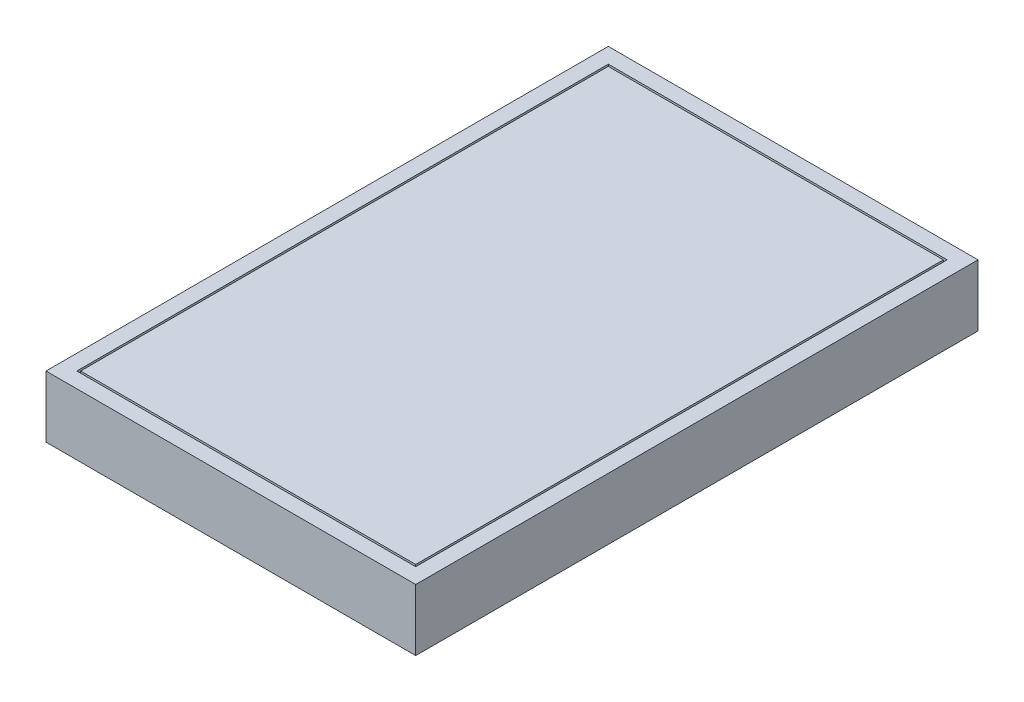
from build123d import *

# Parameters (mm, degrees)
SKETCH1_W           = 480
SKETCH1_H           = 730
BOSS_EXTRUDE1_DEPTH = 80
SKETCH2_W           = 440
SKETCH2_H           = 690
CUT_EXTRUDE1_DEPTH  = 11
SKETCH3_W           = 435
SKETCH3_H           = 685
BOSS_EXTRUDE2_DEPTH = 11


with BuildPart() as part:
    # Sketch1 → Boss-Extrude1 (new body)
    with BuildSketch(Plane.XZ.offset(60)):
        with Locations((0, 365)):
            Rectangle(SKETCH1_W, SKETCH1_H)
    extrude(amount=-BOSS_EXTRUDE1_DEPTH)

    # Sketch2 → Cut-Extrude1 (cut)
    with BuildSketch(Plane(origin=(0, 20, 0), x_dir=(-1, 0, 0), z_dir=(0, 1, 0))):
        with Locations((0, 365)):
            Rectangle(SKETCH2_W, SKETCH2_H)
    extrude(amount=-CUT_EXTRUDE1_DEPTH, mode=Mode.SUBTRACT)

    # Sketch3 → Boss-Extrude2 (add)
    with BuildSketch(Plane(origin=(0, 9, 0), x_dir=(-1, 0, 0), z_dir=(0, 1, 0))):
        with Locations((0, 365)):
            Rectangle(SKETCH3_W, SKETCH3_H)
    extrude(amount=BOSS_EXTRUDE2_DEPTH)


solid = part.part
